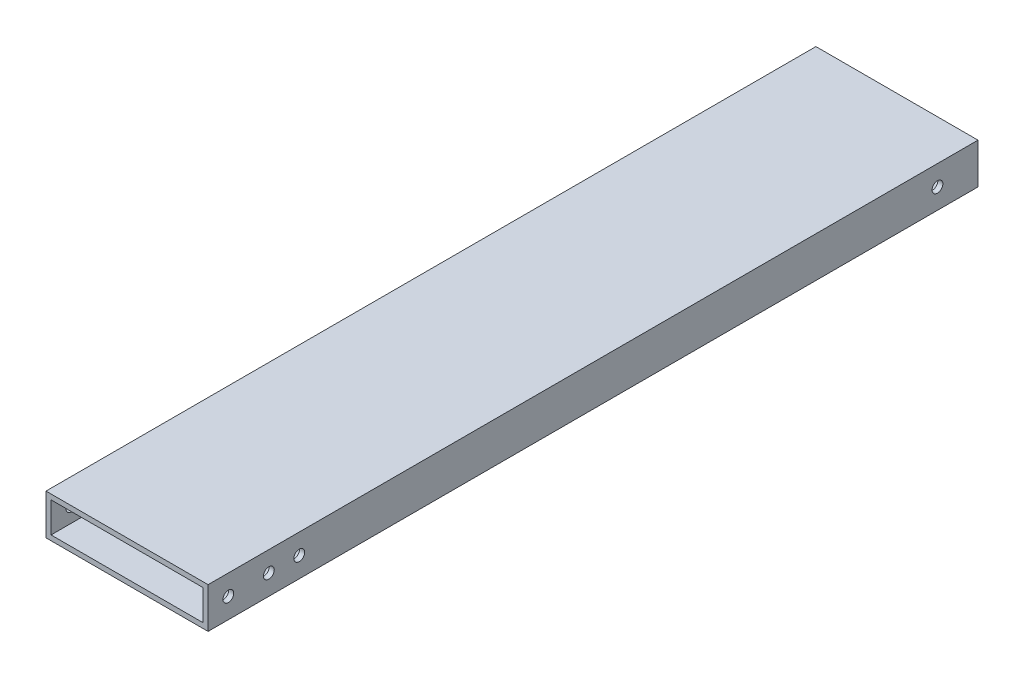
from build123d import *

# Parameters (mm, degrees)
SKETCH1_W                = 101.6
SKETCH1_H                = 25.4
SKETCH1_W_2              = 95.25
SKETCH1_H_2              = 19.05
BOSS_EXTRUDE1_DEPTH      = 482.6
H_0_266_DIAMETER_HOLE1_D = 6.7564


with BuildPart() as part:
    # Sketch1 → Boss-Extrude1 (new body)
    with BuildSketch(Plane.XY):
        Rectangle(SKETCH1_W, SKETCH1_H)
        Rectangle(SKETCH1_W_2, SKETCH1_H_2, mode=Mode.SUBTRACT)
    extrude(amount=BOSS_EXTRUDE1_DEPTH)

    # H (0.266) Diameter Hole1 (through all)
    with Locations(Plane(origin=(50.8, 0, 0), x_dir=(0, 0, -1), z_dir=(1, 0, 0))):
        with Locations((-25.4, 0), (-469.9, 0), (-444.5, 0), (-425.45, 0)):
            Hole(H_0_266_DIAMETER_HOLE1_D / 2)


solid = part.part
